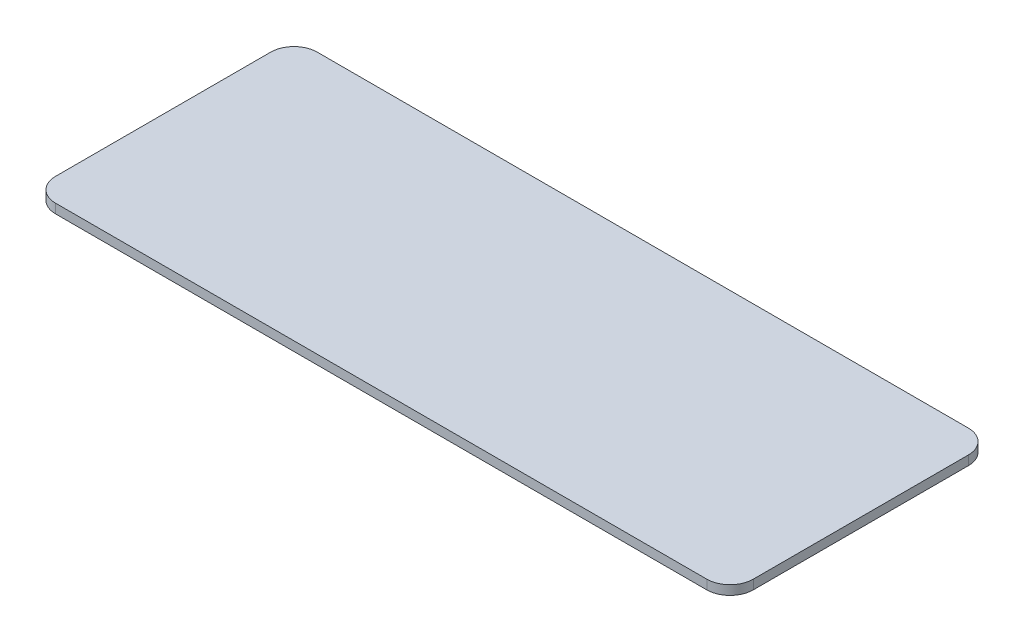
from build123d import *

# Parameters (mm, degrees)
SKETCH1_W           = 120
SKETCH1_H           = 45
BOSS_EXTRUDE1_DEPTH = 1.6
FILLET1_R           = 4


with BuildPart() as part:
    # Sketch1 → Boss-Extrude1 (new body)
    with BuildSketch(Plane(origin=(0, 0, 0), x_dir=(1, 0, 0), z_dir=(0, 1, 0))):
        Rectangle(SKETCH1_W, SKETCH1_H)
    extrude(amount=BOSS_EXTRUDE1_DEPTH)

    # Fillet1
    fillet1_edges = [part.edges().sort_by_distance(p)[0] for p in [
        (60, 0.8, 22.5),
        (-60, 0.8, 22.5),
        (-60, 0.8, -22.5),
        (60, 0.8, -22.5),
    ]]
    fillet(fillet1_edges, radius=FILLET1_R)


solid = part.part
